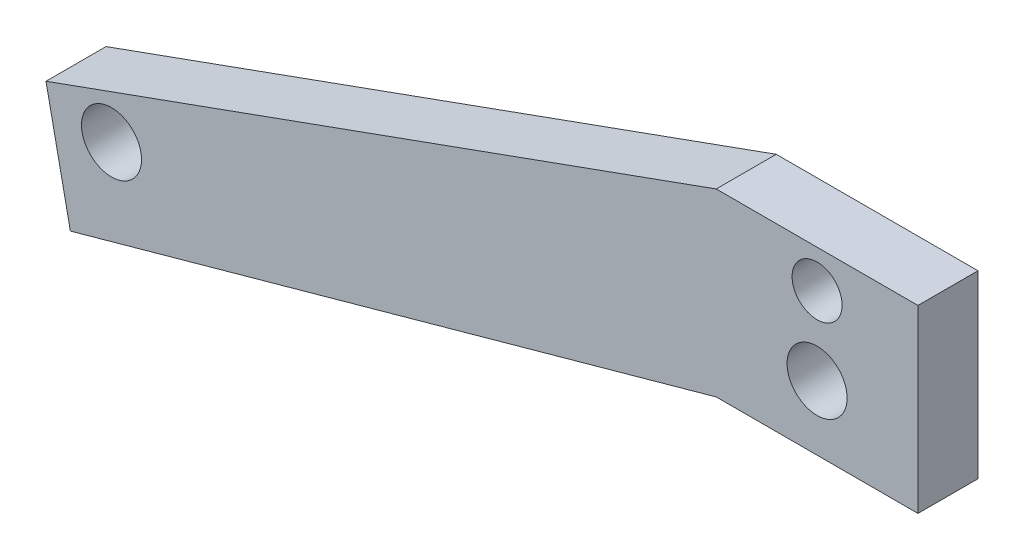
from build123d import *

# Parameters (mm, degrees)
SKETCH1_R           = 3.96875
SKETCH1_R_2         = 4.762500002
BOSS_EXTRUDE1_DEPTH = 9.525


with BuildPart() as part:
    # Sketch1 → Boss-Extrude1 (new body)
    with BuildSketch(Plane.XY):
        Polygon((-15.999988546, 44.999997987), (-122.310094385, 6.64159306), (-118.444110919, -12.012003693), (-15.999988306, 16.424997987), (16.000011454, 16.424997987), (16.000011454, 44.999997987), align=None)
        with Locations((1.1454e-05, 38.999997987)):
            Circle(SKETCH1_R, mode=Mode.SUBTRACT)
        with Locations((1.0942e-05, 26.647593354)):
            Circle(SKETCH1_R_2, mode=Mode.SUBTRACT)
        with Locations((-111.921569578, 3.451692555)):
            Circle(SKETCH1_R_2, mode=Mode.SUBTRACT)
    extrude(amount=BOSS_EXTRUDE1_DEPTH)


solid = part.part
